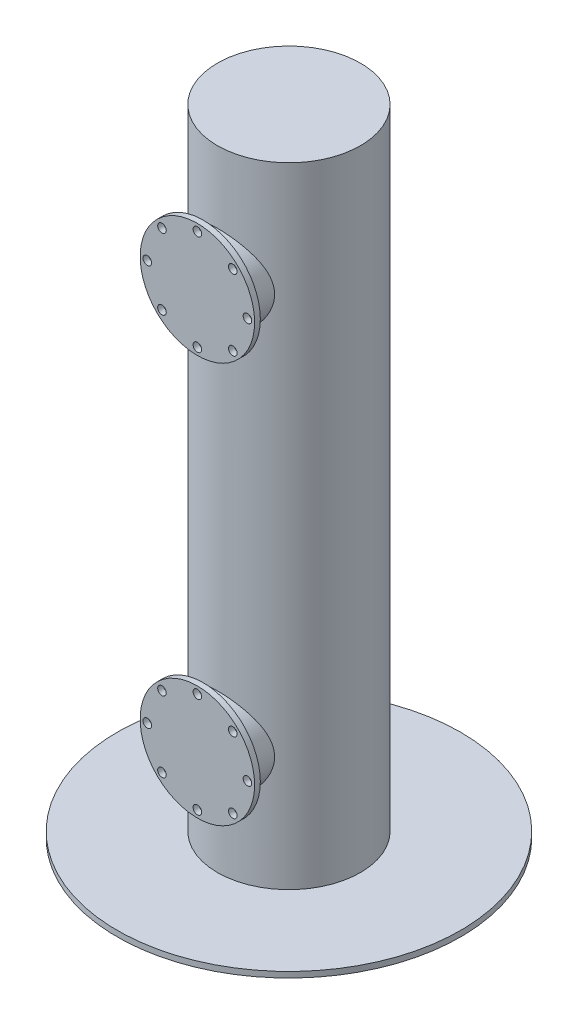
from build123d import *

# Parameters (mm, degrees)
SKETCH1_R           = 25
BOSS_EXTRUDE1_DEPTH = 220
SKETCH2_R           = 15
BOSS_EXTRUDE2_DEPTH = 30
SKETCH3_R           = 20
SKETCH3_R_2         = 1.5
BOSS_EXTRUDE4_DEPTH = 2
SKETCH4_R           = 60
BOSS_EXTRUDE5_DEPTH = 2


with BuildPart() as part:
    # Sketch1 → Boss-Extrude1 (new body)
    with BuildSketch(Plane(origin=(0, 0, 0), x_dir=(1, 0, 0), z_dir=(0, 1, 0))):
        Circle(SKETCH1_R)
    extrude(amount=BOSS_EXTRUDE1_DEPTH)

    # Sketch2 → Boss-Extrude2 (add)
    with BuildSketch(Plane.XY):
        with Locations((0, 180)):
            Circle(SKETCH2_R)
        with Locations((0, 40)):
            Circle(SKETCH2_R)
    extrude(amount=BOSS_EXTRUDE2_DEPTH)

    # Sketch3 → Boss-Extrude4 (add)
    with BuildSketch(Plane.XY.offset(30)):
        with Locations((0, 180)):
            Circle(SKETCH3_R)
        with Locations((0, 197.5)):
            Circle(SKETCH3_R_2, mode=Mode.SUBTRACT)
        with Locations((12.374368671, 192.374368671)):
            Circle(SKETCH3_R_2, mode=Mode.SUBTRACT)
        with Locations((17.5, 180)):
            Circle(SKETCH3_R_2, mode=Mode.SUBTRACT)
        with Locations((12.374368671, 167.625631329)):
            Circle(SKETCH3_R_2, mode=Mode.SUBTRACT)
        with Locations((0, 162.5)):
            Circle(SKETCH3_R_2, mode=Mode.SUBTRACT)
        with Locations((-12.374368671, 167.625631329)):
            Circle(SKETCH3_R_2, mode=Mode.SUBTRACT)
        with Locations((-17.5, 180)):
            Circle(SKETCH3_R_2, mode=Mode.SUBTRACT)
        with Locations((-12.374368671, 192.374368671)):
            Circle(SKETCH3_R_2, mode=Mode.SUBTRACT)
        with Locations((0, 40)):
            Circle(SKETCH3_R)
        with Locations((0, 57.5)):
            Circle(SKETCH3_R_2, mode=Mode.SUBTRACT)
        with Locations((12.374368671, 52.374368671)):
            Circle(SKETCH3_R_2, mode=Mode.SUBTRACT)
        with Locations((17.5, 40)):
            Circle(SKETCH3_R_2, mode=Mode.SUBTRACT)
        with Locations((12.374368671, 27.625631329)):
            Circle(SKETCH3_R_2, mode=Mode.SUBTRACT)
        with Locations((0, 22.5)):
            Circle(SKETCH3_R_2, mode=Mode.SUBTRACT)
        with Locations((-12.374368671, 27.625631329)):
            Circle(SKETCH3_R_2, mode=Mode.SUBTRACT)
        with Locations((-17.5, 40)):
            Circle(SKETCH3_R_2, mode=Mode.SUBTRACT)
        with Locations((-12.374368671, 52.374368671)):
            Circle(SKETCH3_R_2, mode=Mode.SUBTRACT)
    extrude(amount=BOSS_EXTRUDE4_DEPTH)

    # Sketch4 → Boss-Extrude5 (add)
    with BuildSketch(Plane.XZ):
        Circle(SKETCH4_R)
    extrude(amount=BOSS_EXTRUDE5_DEPTH)


solid = part.part
